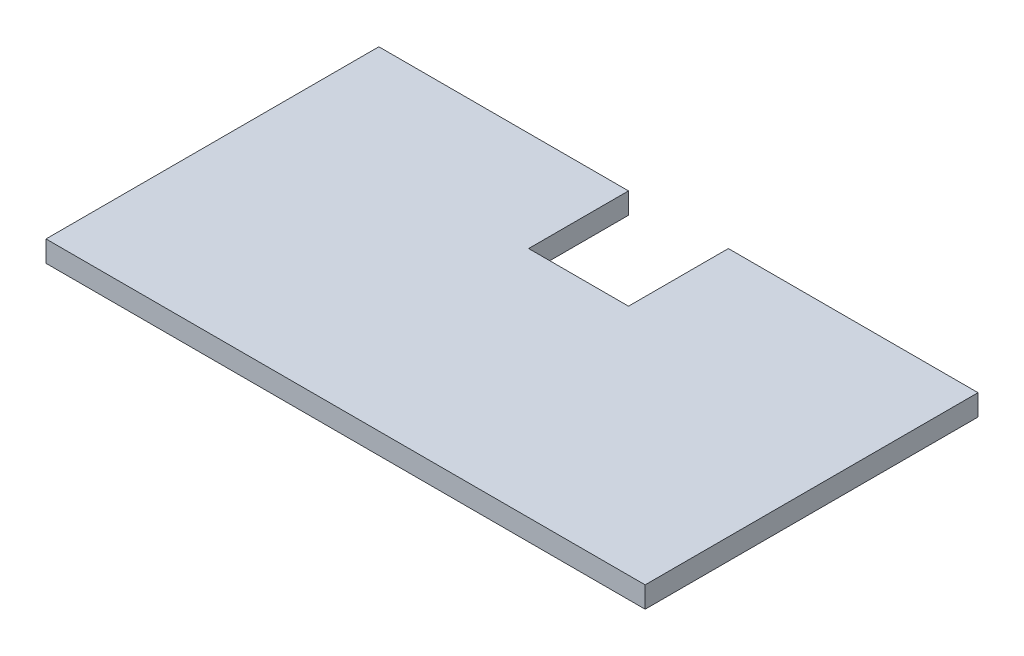
from build123d import *

# Parameters (mm, degrees)
SKETCH1_W           = 90
SKETCH1_H           = 50
BOSS_EXTRUDE1_DEPTH = 3.175
SKETCH2_W           = 15
SKETCH2_H           = 15
CUT_EXTRUDE1_DEPTH  = 4.175


with BuildPart() as part:
    # Sketch1 → Boss-Extrude1 (new body)
    with BuildSketch(Plane(origin=(0, 0, 0), x_dir=(1, 0, 0), z_dir=(0, 1, 0))):
        Rectangle(SKETCH1_W, SKETCH1_H)
    extrude(amount=BOSS_EXTRUDE1_DEPTH)

    # Sketch2 → Cut-Extrude1 (cut, through all)
    with BuildSketch(Plane(origin=(0, 3.175, 0), x_dir=(1, 0, 0), z_dir=(0, 1, 0))):
        with Locations((0, 17.5)):
            Rectangle(SKETCH2_W, SKETCH2_H)
    extrude(amount=-CUT_EXTRUDE1_DEPTH, mode=Mode.SUBTRACT)


solid = part.part
